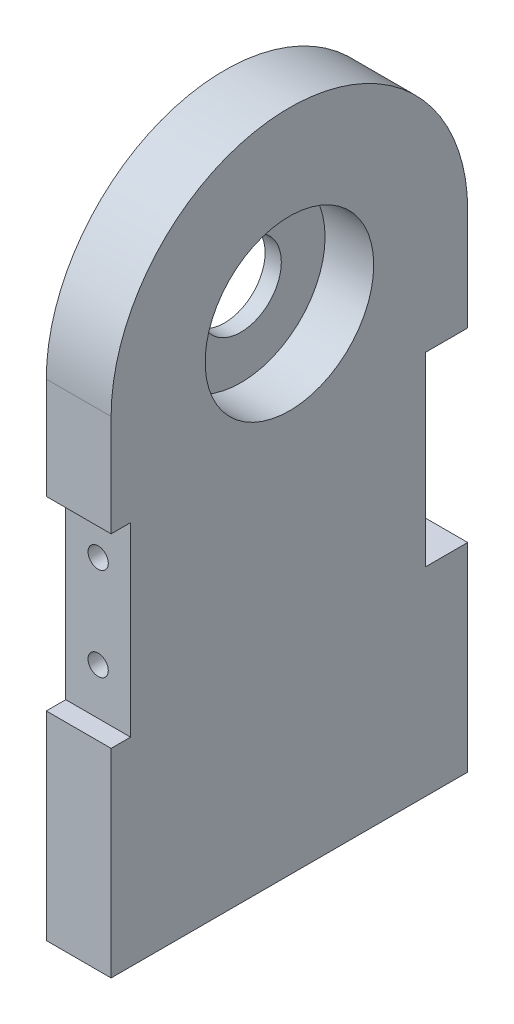
from build123d import *

# Parameters (mm, degrees)
BOSS_EXTRUDE1_DEPTH              = 20
SKETCH3_R                        = 26
CUT_EXTRUDE1_DEPTH               = 15
SKETCH4_R                        = 12.5
CUT_EXTRUDE2_DEPTH               = 11.1125
TAP_DRILL_FOR_M6X1_0_TAP2_D      = 5
TAP_DRILL_FOR_M6X1_0_TAP2_DEPTH  = 40
TAP_DRILL_FOR_M6X1_0_TAP2_TIP    = 1.502151548
SKETCH12_W                       = 6
SKETCH12_H                       = 57.3
SKETCH12_W_2                     = 13
CUT_EXTRUDE3_DEPTH               = 20
TAP_DRILL_FOR_M6_HELICOIL1_D     = 6.25
TAP_DRILL_FOR_M6_HELICOIL1_DEPTH = 20
TAP_DRILL_FOR_M6_HELICOIL1_TIP   = 1.877689434
TAP_DRILL_FOR_M6_HELICOIL2_D     = 6.25
TAP_DRILL_FOR_M6_HELICOIL2_DEPTH = 20
TAP_DRILL_FOR_M6_HELICOIL2_TIP   = 1.877689434


with BuildPart() as part:
    # Sketch2 → Boss-Extrude1 (new body)
    with BuildSketch(Plane(origin=(0, 0, 0), x_dir=(0, 0, -1), z_dir=(1, 0, 0))):
        with BuildLine():
            Line((55, -75), (55, 75))
            ThreePointArc((55, 75), (0, 20), (-55, 75))
            Line((-55, 75), (-55, -75))
            Line((-55, -75), (55, -75))
        make_face()
        with BuildLine():
            ThreePointArc((-55, 75), (0, 20), (55, 75))
            Line((55, 75), (-55, 75))
        make_face()
        with BuildLine():
            Line((-55, 75), (55, 75))
            ThreePointArc((55, 75), (0, 130), (-55, 75))
        make_face()
    extrude(amount=BOSS_EXTRUDE1_DEPTH)

    # Sketch3 → Cut-Extrude1 (cut)
    with BuildSketch(Plane(origin=(20, 0, 0), x_dir=(0, 0, -1), z_dir=(1, 0, 0))):
        with Locations((0, 75)):
            Circle(SKETCH3_R)
    extrude(amount=-CUT_EXTRUDE1_DEPTH, mode=Mode.SUBTRACT)

    # Sketch4 → Cut-Extrude2 (cut)
    with BuildSketch(Plane(origin=(5, 0, 0), x_dir=(0, 0, -1), z_dir=(1, 0, 0))):
        with Locations((0, 75)):
            Circle(SKETCH4_R)
    extrude(amount=-CUT_EXTRUDE2_DEPTH, mode=Mode.SUBTRACT)

    # Tap Drill for M6x1.0 Tap2
    with Locations(Plane(origin=(0, -75, 0), x_dir=(-1, 0, 0), z_dir=(0, -1, 0))):
        with Locations((-10, -36.666666667), (-10, -18.333333333), (-10, 0), (-10, 18.333333333), (-10, 36.666666667)):
            Hole(TAP_DRILL_FOR_M6X1_0_TAP2_D / 2, depth=TAP_DRILL_FOR_M6X1_0_TAP2_DEPTH)
            with Locations((0, 0, -(TAP_DRILL_FOR_M6X1_0_TAP2_DEPTH + TAP_DRILL_FOR_M6X1_0_TAP2_TIP / 2))):  # 118° drill point
                Cone(0, TAP_DRILL_FOR_M6X1_0_TAP2_D / 2, TAP_DRILL_FOR_M6X1_0_TAP2_TIP, mode=Mode.SUBTRACT)

    # Sketch12 → Cut-Extrude3 (cut)
    with BuildSketch(Plane(origin=(20, 0, 0), x_dir=(0, 0, -1), z_dir=(1, 0, 0))):
        with Locations((-52, 15)):
            Rectangle(SKETCH12_W, SKETCH12_H)
        with Locations((48.5, 15)):
            Rectangle(SKETCH12_W_2, SKETCH12_H)
    extrude(amount=-CUT_EXTRUDE3_DEPTH, mode=Mode.SUBTRACT)

    # Tap Drill for M6 Helicoil1
    with Locations(Plane(origin=(10, 29.325, 49), x_dir=(1, 0, 0), z_dir=(0, 0, 1))):
        with Locations((0, 0), (0, -28.65)):
            Hole(TAP_DRILL_FOR_M6_HELICOIL1_D / 2, depth=TAP_DRILL_FOR_M6_HELICOIL1_DEPTH)
            with Locations((0, 0, -(TAP_DRILL_FOR_M6_HELICOIL1_DEPTH + TAP_DRILL_FOR_M6_HELICOIL1_TIP / 2))):  # 118° drill point
                Cone(0, TAP_DRILL_FOR_M6_HELICOIL1_D / 2, TAP_DRILL_FOR_M6_HELICOIL1_TIP, mode=Mode.SUBTRACT)

    # Tap Drill for M6 Helicoil2
    with Locations(Plane(origin=(0, 0, -42), x_dir=(-1, 0, 0), z_dir=(0, 0, -1))):
        with Locations((-10, 29.325), (-10, 0.675)):
            Hole(TAP_DRILL_FOR_M6_HELICOIL2_D / 2, depth=TAP_DRILL_FOR_M6_HELICOIL2_DEPTH)
            with Locations((0, 0, -(TAP_DRILL_FOR_M6_HELICOIL2_DEPTH + TAP_DRILL_FOR_M6_HELICOIL2_TIP / 2))):  # 118° drill point
                Cone(0, TAP_DRILL_FOR_M6_HELICOIL2_D / 2, TAP_DRILL_FOR_M6_HELICOIL2_TIP, mode=Mode.SUBTRACT)


solid = part.part
